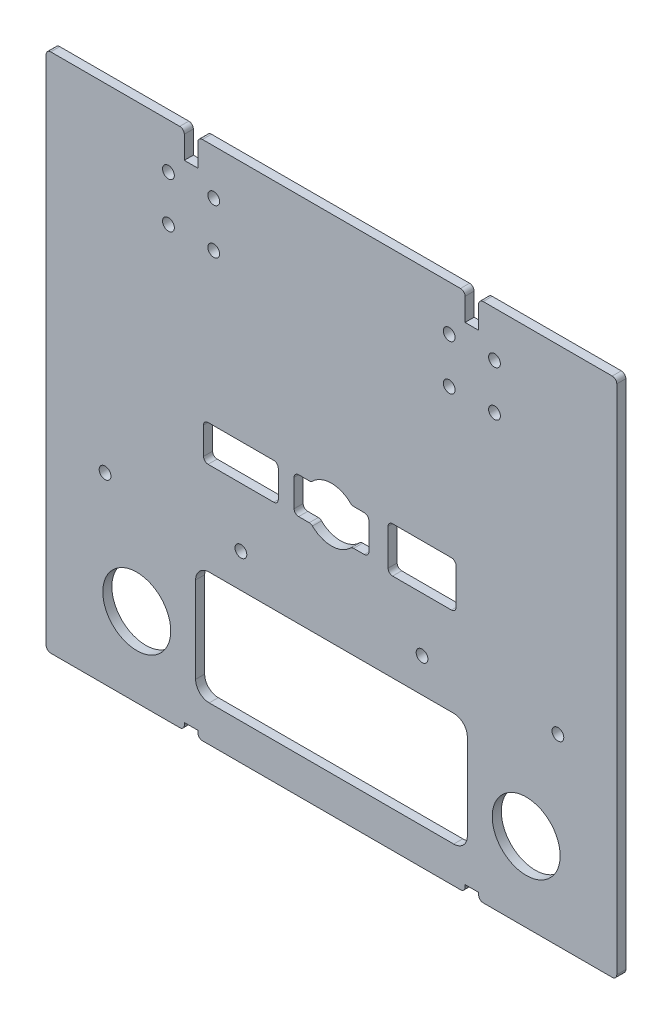
from build123d import *

# Parameters (mm, degrees)
SKETCH1_W           = 126
SKETCH1_H           = 115
BOSS_EXTRUDE1_DEPTH = 2
SKETCH2_R           = 7.5
SKETCH2_W           = 60
SKETCH2_H           = 25
CUT_EXTRUDE1_DEPTH  = 2
FILLET1_R           = 3
SKETCH3_R           = 1.3
CUT_EXTRUDE2_DEPTH  = 4
SKETCH4_W           = 3
SKETCH4_H           = 6
SKETCH4_H_2         = 1.5
CUT_EXTRUDE3_DEPTH  = 10
FILLET2_R           = 1
SKETCH6_W           = 15
SKETCH6_H           = 10
SKETCH6_W_2         = 16.5
SKETCH6_H_2         = 8
CUT_EXTRUDE5_DEPTH  = 10
FILLET3_R           = 1
SKETCH7_R           = 1.3
CUT_EXTRUDE6_DEPTH  = 2.5


with BuildPart() as part:
    # Sketch1 → Boss-Extrude1 (new body)
    with BuildSketch(Plane.XY):
        Rectangle(SKETCH1_W, SKETCH1_H)
    extrude(amount=BOSS_EXTRUDE1_DEPTH)

    # Sketch2 → Cut-Extrude1 (cut)
    with BuildSketch(Plane.XY.offset(2)):
        with Locations((-43, -40)):
            Circle(SKETCH2_R)
        with Locations((43, -40)):
            Circle(SKETCH2_R)
        with Locations((0, -37)):
            Rectangle(SKETCH2_W, SKETCH2_H)
    extrude(amount=-CUT_EXTRUDE1_DEPTH, mode=Mode.SUBTRACT)

    # Fillet1
    fillet1_edges = [part.edges().sort_by_distance(p)[0] for p in [
        (30, -24.5, 1),
        (30, -49.5, 1),
        (-30, -49.5, 1),
        (-30, -24.5, 1),
    ]]
    fillet(fillet1_edges, radius=FILLET1_R)

    # Sketch3 → Cut-Extrude2 (cut)
    with BuildSketch(Plane.XY.offset(2)):
        with Locations((-26, 47.5)):
            Circle(SKETCH3_R)
        with Locations((-36, 47.5)):
            Circle(SKETCH3_R)
        with Locations((36, 47.5)):
            Circle(SKETCH3_R)
        with Locations((26, 47.5)):
            Circle(SKETCH3_R)
        with Locations((-26, 37.5)):
            Circle(SKETCH3_R)
        with Locations((-36, 37.5)):
            Circle(SKETCH3_R)
        with Locations((36, 37.5)):
            Circle(SKETCH3_R)
        with Locations((26, 37.5)):
            Circle(SKETCH3_R)
    extrude(amount=-CUT_EXTRUDE2_DEPTH, mode=Mode.SUBTRACT)

    # Sketch4 → Cut-Extrude3 (cut)
    with BuildSketch(Plane(origin=(0, 0, 0), x_dir=(-1, 0, 0), z_dir=(0, 0, -1))):
        with Locations((-31, 54.5)):
            Rectangle(SKETCH4_W, SKETCH4_H)
        with Locations((31, 54.5)):
            Rectangle(SKETCH4_W, SKETCH4_H)
        with Locations((31, -56.75)):
            Rectangle(SKETCH4_W, SKETCH4_H_2)
        with Locations((-31, -56.75)):
            Rectangle(SKETCH4_W, SKETCH4_H_2)
    extrude(amount=-CUT_EXTRUDE3_DEPTH, mode=Mode.SUBTRACT)

    # Fillet2
    fillet2_edges = [part.edges().sort_by_distance(p)[0] for p in [
        (-29.5, -57.5, 1),
        (-32.5, -57.5, 1),
        (29.5, -57.5, 1),
        (32.5, -57.5, 1),
        (29.5, 57.5, 1),
        (32.5, 57.5, 1),
        (-32.5, 57.5, 1),
        (-29.5, 57.5, 1),
        (63, -57.5, 1),
        (-63, -57.5, 1),
        (-63, 57.5, 1),
        (63, 57.5, 1),
    ]]
    fillet(fillet2_edges, radius=FILLET2_R)

    # Sketch6 → Cut-Extrude5 (cut)
    with BuildSketch(Plane.XY.offset(2)):
        with Locations((20, 0)):
            Rectangle(SKETCH6_W, SKETCH6_H)
        with BuildLine():
            Line((4.472135955, 4), (-4.472135955, 4))
            ThreePointArc((-4.472135955, 4), (-6, 0), (-4.472135955, -4))
            Line((-4.472135955, -4), (4.472135955, -4))
            ThreePointArc((4.472135955, -4), (5.605034154, -2.140932539), (6, 0))
            ThreePointArc((6, 0), (5.605034154, 2.140932539), (4.472135955, 4))
        make_face()
        with BuildLine():
            Line((8.25, 4), (4.472135955, 4))
            ThreePointArc((4.472135955, 4), (5.605034154, 2.140932539), (6, 0))
            ThreePointArc((6, 0), (5.605034154, -2.140932539), (4.472135955, -4))
            Line((4.472135955, -4), (8.25, -4))
            Line((8.25, -4), (8.25, 4))
        make_face()
        with BuildLine():
            ThreePointArc((4.472135955, 4), (0, 6), (-4.472135955, 4))
            Line((-4.472135955, 4), (4.472135955, 4))
        make_face()
        with BuildLine():
            Line((-4.472135955, 4), (-8.25, 4))
            Line((-8.25, 4), (-8.25, -4))
            Line((-8.25, -4), (-4.472135955, -4))
            ThreePointArc((-4.472135955, -4), (-6, 0), (-4.472135955, 4))
        make_face()
        with BuildLine():
            Line((4.472135955, -4), (-4.472135955, -4))
            ThreePointArc((-4.472135955, -4), (0, -6), (4.472135955, -4))
        make_face()
        with Locations((-20, 0)):
            Rectangle(SKETCH6_W_2, SKETCH6_H_2)
    extrude(amount=-CUT_EXTRUDE5_DEPTH, mode=Mode.SUBTRACT)

    # Fillet3
    fillet3_edges = [part.edges().sort_by_distance(p)[0] for p in [
        (27.5, 5, 1),
        (27.5, -5, 1),
        (12.5, -5, 1),
        (12.5, 5, 1),
        (4.472135955, 4, 1),
        (8.25, 4, 1),
        (8.25, -4, 1),
        (4.472135955, -4, 1),
        (-4.472135955, -4, 1),
        (-8.25, -4, 1),
        (-8.25, 4, 1),
        (-4.472135955, 4, 1),
        (-11.75, 4, 1),
        (-11.75, -4, 1),
        (-28.25, -4, 1),
        (-28.25, 4, 1),
    ]]
    fillet(fillet3_edges, radius=FILLET3_R)

    # Sketch7 → Cut-Extrude6 (cut)
    with BuildSketch(Plane(origin=(0, 0, 0), x_dir=(-1, 0, 0), z_dir=(0, 0, -1))):
        with Locations((-50, -17)):
            Circle(SKETCH7_R)
        with Locations((-20, -17)):
            Circle(SKETCH7_R)
        with Locations((20, -17)):
            Circle(SKETCH7_R)
        with Locations((50, -17)):
            Circle(SKETCH7_R)
    extrude(amount=-CUT_EXTRUDE6_DEPTH, mode=Mode.SUBTRACT)


solid = part.part
